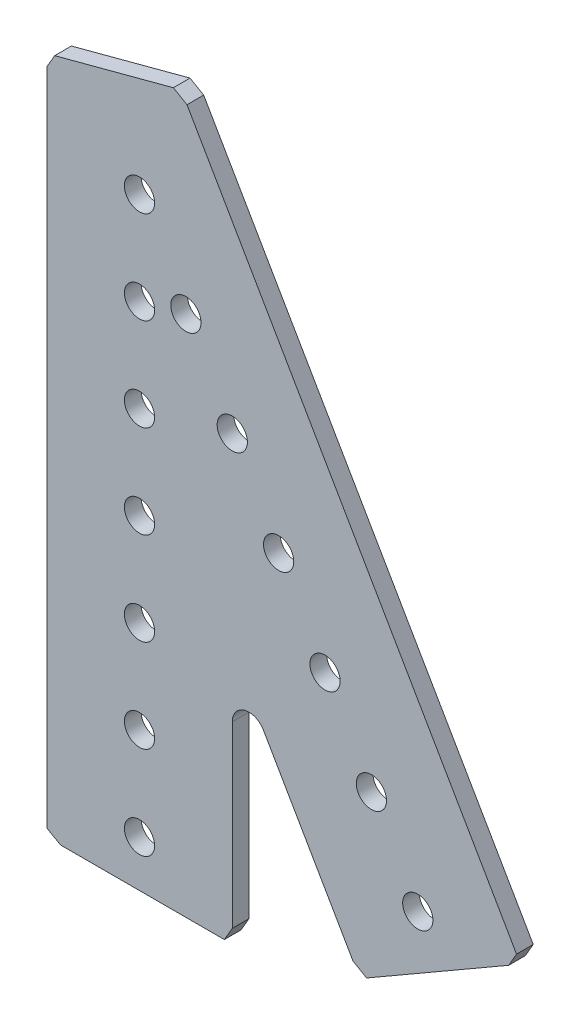
from build123d import *

# Parameters (mm, degrees)
SKETCH1_R           = 2.0701
BOSS_EXTRUDE1_DEPTH = 2.286


with BuildPart() as part:
    # Sketch1 → Boss-Extrude1 (new body)
    with BuildSketch(Plane(origin=(0, 0, 0), x_dir=(-1, 0, 0), z_dir=(0, 0, -1))):
        with BuildLine():
            Line((-29.230637652, -76.282949552), (-16.965734073, -55.039513402))
            ThreePointArc((-16.965734073, -55.039513402), (-14.394339663, -53.974406963), (-12.7, -56.182513402))
            Line((-12.7, -56.182513402), (-12.7, -80.682217477))
            Line((-12.7, -80.682217477), (-11.617101368, -82.55))
            Line((-11.617101368, -82.55), (10.832217477, -82.55))
            Line((10.832217477, -82.55), (12.7, -81.467101368))
            Line((12.7, -81.467101368), (12.7, 8.779535349))
            Line((12.7, 8.779535349), (11.617101368, 10.647317872))
            Line((11.617101368, 10.647317872), (-4.632676327, 14.969773631))
            Line((-4.632676327, 14.969773631), (-6.50045885, 13.886874999))
            Line((-6.50045885, 13.886874999), (-51.625488503, -64.271969053))
            Line((-51.625488503, -64.271969053), (-50.542589871, -66.139751576))
            Line((-50.542589871, -66.139751576), (-31.098420176, -77.365848184))
            Line((-31.098420176, -77.365848184), (-29.230637652, -76.282949552))
        make_face()
        with Locations((-38.1, -65.991135768)):
            Circle(SKETCH1_R, mode=Mode.SUBTRACT)
        with Locations((0, -63.5)):
            Circle(SKETCH1_R, mode=Mode.SUBTRACT)
        with Locations((-25.4, -43.994090512)):
            Circle(SKETCH1_R, mode=Mode.SUBTRACT)
        with Locations((-12.7, -21.997045256)):
            Circle(SKETCH1_R, mode=Mode.SUBTRACT)
        with Locations((0, -38.1)):
            Circle(SKETCH1_R, mode=Mode.SUBTRACT)
        with Locations((0, -12.7)):
            Circle(SKETCH1_R, mode=Mode.SUBTRACT)
        Circle(SKETCH1_R, mode=Mode.SUBTRACT)
        with Locations((-6.35, -10.998522628)):
            Circle(SKETCH1_R, mode=Mode.SUBTRACT)
        with Locations((0, -25.4)):
            Circle(SKETCH1_R, mode=Mode.SUBTRACT)
        with Locations((0, -50.8)):
            Circle(SKETCH1_R, mode=Mode.SUBTRACT)
        with Locations((-19.05, -32.995567884)):
            Circle(SKETCH1_R, mode=Mode.SUBTRACT)
        with Locations((-31.75, -54.99261314)):
            Circle(SKETCH1_R, mode=Mode.SUBTRACT)
        with Locations((0, -76.2)):
            Circle(SKETCH1_R, mode=Mode.SUBTRACT)
    extrude(amount=-BOSS_EXTRUDE1_DEPTH)


solid = part.part
